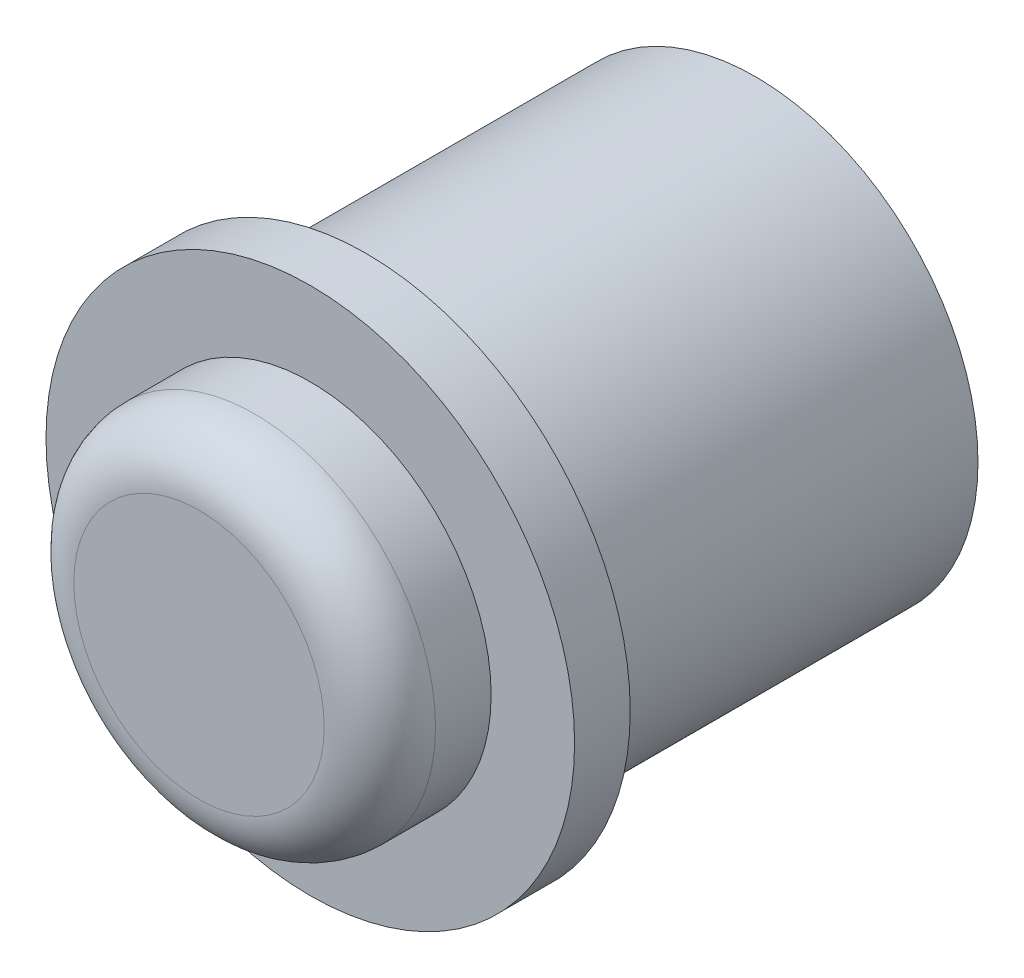
from build123d import *

# Parameters (mm, degrees)
SKETCH1_R           = 8
BOSS_EXTRUDE1_DEPTH = 14
SKETCH2_R           = 9.5
BOSS_EXTRUDE2_DEPTH = 2
SKETCH3_R           = 6.5
BOSS_EXTRUDE3_DEPTH = 4
FILLET1_R           = 2


with BuildPart() as part:
    # Sketch1 → Boss-Extrude1 (new body)
    with BuildSketch(Plane.XY):
        Circle(SKETCH1_R)
    extrude(amount=BOSS_EXTRUDE1_DEPTH)

    # Sketch2 → Boss-Extrude2 (add)
    with BuildSketch(Plane.XY.offset(14)):
        Circle(SKETCH2_R)
    extrude(amount=BOSS_EXTRUDE2_DEPTH)

    # Sketch3 → Boss-Extrude3 (add)
    with BuildSketch(Plane.XY.offset(16)):
        Circle(SKETCH3_R)
    extrude(amount=BOSS_EXTRUDE3_DEPTH)

    # Fillet1
    fillet1_edges = [part.edges().sort_by_distance(p)[0] for p in [
        (-6.5, 0, 20),
    ]]
    fillet(fillet1_edges, radius=FILLET1_R)


solid = part.part
